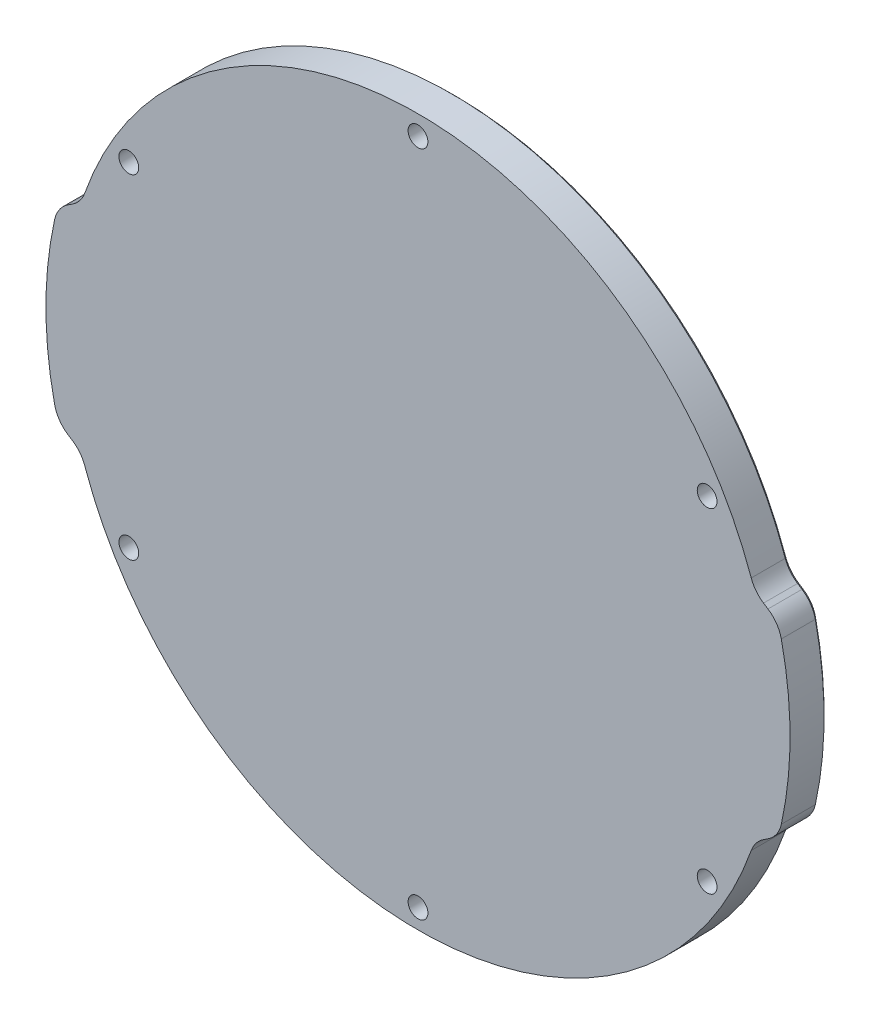
from build123d import *

# Parameters (mm, degrees)
EXTRUDE_1_DEPTH             = 6
CUT_EXTRUDE_1_DEPTH         = 7
HOLE_WIZARD_3_2_3_2_1_D     = 3.2
HOLE_WIZARD_3_2_3_2_1_DEPTH = 6
FILLET_1_R                  = 5
CHAMFER_1_SIZE              = 0.5


with BuildPart() as part:
    # 草图1 → 凸台-拉伸1 (new body)
    with BuildSketch(Plane.XY.offset(6)):
        with BuildLine():
            Line((-54.404710274, 17.5), (-58.249656651, 15))
            ThreePointArc((-58.249656651, 15), (0, -60.15), (58.249656651, 15))
            Line((58.249656651, 15), (54.404710274, 17.5))
            ThreePointArc((54.404710274, 17.5), (0, 57.15), (-54.404710274, 17.5))
        make_face()
    extrude(amount=-EXTRUDE_1_DEPTH)

    # 草图2 → 切除-拉伸1 (cut, through all)
    with BuildSketch(Plane(origin=(0, 0, 0), x_dir=(-1, 0, 0), z_dir=(0, 0, -1))):
        with BuildLine():
            Line((58.249656651, -15), (54.404710274, -17.5))
            ThreePointArc((54.404710274, -17.5), (0, -57.15), (-54.404710274, -17.5))
            Line((-54.404710274, -17.5), (-58.249656651, -15))
            ThreePointArc((-58.249656651, -15), (0, -60.15), (58.249656651, -15))
        make_face()
    extrude(amount=-CUT_EXTRUDE_1_DEPTH, mode=Mode.SUBTRACT)

    # Ø3.2 (3.2) 直径孔1
    with Locations(Plane(origin=(0, 0, 0), x_dir=(-1, 0, 0), z_dir=(0, 0, -1))):
        with Locations((0, 53.975), (46.743721169, -26.9875), (-46.743721169, 26.9875), (-46.743721169, -26.9875), (0, -53.975), (46.743721169, 26.9875)):
            Hole(HOLE_WIZARD_3_2_3_2_1_D / 2, depth=HOLE_WIZARD_3_2_3_2_1_DEPTH)

    # 圆角1
    fillet_1_edges = [part.edges().sort_by_distance(p)[0] for p in [
        (-58.249656651, -15, 3),
        (58.249656651, -15, 3),
        (54.404710274, -17.5, 3),
        (-54.404710274, -17.5, 3),
        (54.404710274, 17.5, 3),
        (58.249656651, 15, 3),
        (-58.249656651, 15, 3),
        (-54.404710274, 17.5, 3),
    ]]
    fillet(fillet_1_edges, radius=FILLET_1_R)

    # 倒角1
    chamfer_1_edges = [part.edges().sort_by_distance(p)[0] for p in [
        (0, -57.15, 0),
        (-56.218559502, -16.320627747, 0),
        (60.15, 0, 0),
        (56.218559502, 16.320627747, 0),
        (56.218559502, -16.320627747, 0),
        (-60.15, 0, 0),
        (-56.218559502, 16.320627747, 0),
        (0, 57.15, 0),
        (-57.961950962, 14.742761538, 0),
        (57.961950962, -14.742761538, 0),
        (-57.961950962, -14.742761538, 0),
        (57.961950962, 14.742761538, 0),
        (-54.657828511, -17.651398409, 0),
        (54.657828511, -17.651398409, 0),
        (54.657828511, 17.651398409, 0),
        (-54.657828511, 17.651398409, 0),
    ]]
    chamfer(chamfer_1_edges, length=CHAMFER_1_SIZE)


solid = part.part
